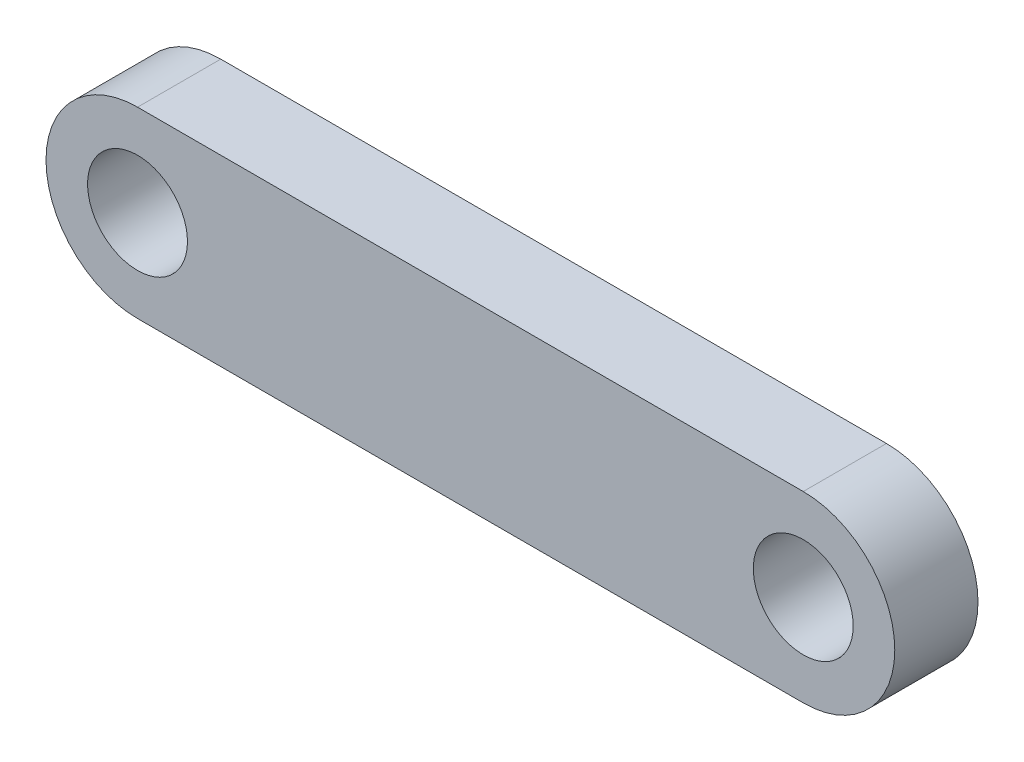
from build123d import *

# Parameters (mm, degrees)
SKETCH1_R           = 3
BOSS_EXTRUDE1_DEPTH = 2.5


with BuildPart() as part:
    # Sketch1 → Boss-Extrude1 (new body, symmetric)
    with BuildSketch(Plane.XY):
        with BuildLine():
            Line((-20, 5.5), (20, 5.5))
            ThreePointArc((20, 5.5), (25.5, 0), (20, -5.5))
            Line((20, -5.5), (-20, -5.5))
            ThreePointArc((-20, -5.5), (-25.5, 0), (-20, 5.5))
        make_face()
        with Locations((-20, 0)):
            Circle(SKETCH1_R, mode=Mode.SUBTRACT)
        with Locations((20, 0)):
            Circle(SKETCH1_R, mode=Mode.SUBTRACT)
    extrude(amount=BOSS_EXTRUDE1_DEPTH, both=True)


solid = part.part
